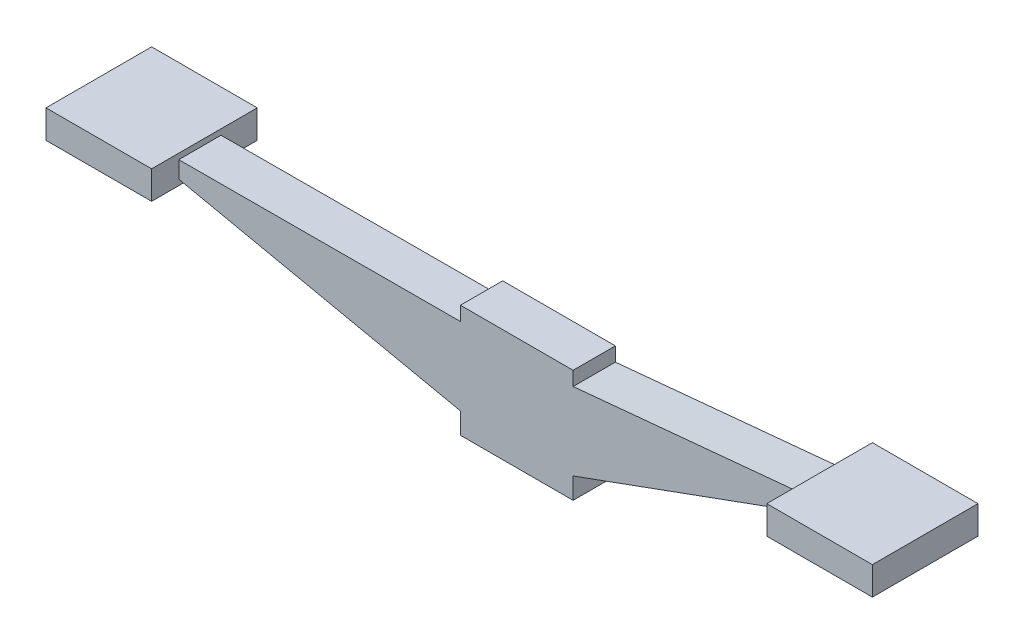
from build123d import *

# Parameters (mm, degrees)
BOSS_EXTRUDE1_DEPTH = 15
SKETCH2_W           = 75
SKETCH2_H           = 75
BOSS_EXTRUDE2_DEPTH = 20
SKETCH3_W           = 75
SKETCH3_H           = 75
BOSS_EXTRUDE3_DEPTH = 20


with BuildPart() as part:
    # Sketch1 → Boss-Extrude1 (new body, symmetric)
    with BuildSketch(Plane.XY):
        Polygon((-40, -25), (-40, -40), (40, -40), (40, -25), (200, 33.235237483), (200, 29.235237483), (257, 29.235237483), (257, 49.235237483), (200, 49.235237483), (200, 45.235237483), (40, 30), (40, 40), (-40, 40), (-40, 30), (-240, 29.511312334), (-240, 33.511312334), (-297, 33.511312334), (-297, 13.511312334), (-240, 13.511312334), (-240, 17.511312334), align=None)
    extrude(amount=BOSS_EXTRUDE1_DEPTH, both=True)

    # Sketch2 → Boss-Extrude2 (add)
    with BuildSketch(Plane(origin=(0, 33.511312334, 0), x_dir=(1, 0, 0), z_dir=(0, 1, 0))):
        with Locations((-277.5, 3.224825952)):
            Rectangle(SKETCH2_W, SKETCH2_H)
    extrude(amount=-BOSS_EXTRUDE2_DEPTH)

    # Sketch3 → Boss-Extrude3 (add)
    with BuildSketch(Plane(origin=(0, 49.235237483, 0), x_dir=(1, 0, 0), z_dir=(0, 1, 0))):
        with Locations((237.5, 0)):
            Rectangle(SKETCH3_W, SKETCH3_H)
    extrude(amount=-BOSS_EXTRUDE3_DEPTH)


solid = part.part
